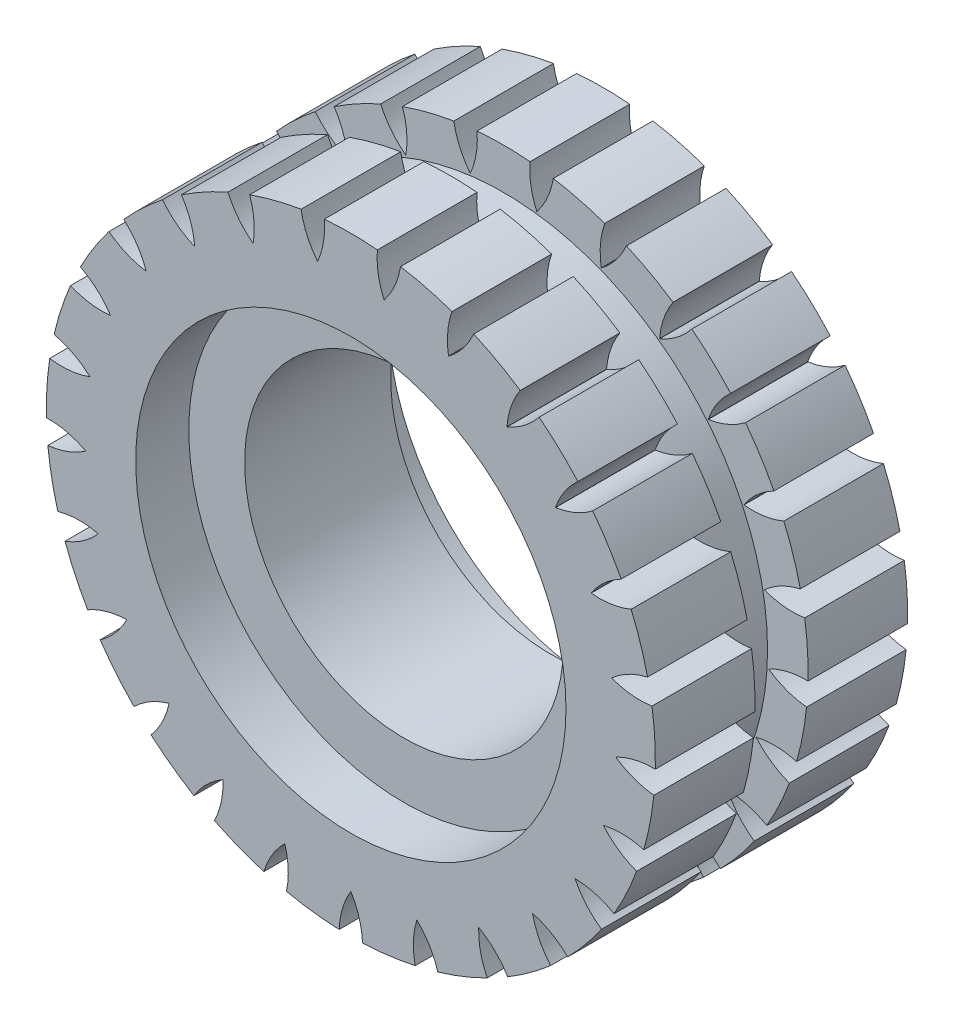
from build123d import *

# Parameters (mm, degrees)
AUFSATZ_LINEAR_AUSTRAGEN1_DEPTH = 19
SKIZZE3_W                       = 4
SKIZZE3_H                       = 3.501683852


with BuildPart() as part:
    # Skizze1 → Rotation1 (revolve)
    with BuildSketch(Plane(origin=(0, 0, 0), x_dir=(0, 0, -1), z_dir=(1, 0, 0))):
        Polygon((-5.5, 0), (5.5, 0), (5.5, 4.2), (9.5, 4.2), (9.5, 8), (-9.5, 8), (-9.5, 4.2), (-5.5, 4.2), align=None)
    revolve(axis=Axis((0, -12, 19.330416941), (0, 0, -1)))

    # Skizze2 → Aufsatz-Linear austragen1 (add, through all)
    with BuildSketch(Plane.XY.offset(9.5)):
        with BuildLine():
            ThreePointArc((-2.5, 7.843134833), (0, 8), (2.5, 7.843134833))
            ThreePointArc((2.5, 7.843134833), (2.059627906, 9.311406151), (2, 10.843134833))
            ThreePointArc((2, 10.843134833), (0, 10.930521342), (-2, 10.843134833))
            ThreePointArc((-2, 10.843134833), (-2.059627906, 9.311406151), (-2.5, 7.843134833))
        make_face()
        with BuildLine():
            ThreePointArc((3.743690302, 10.622855521), (5.702588765, 10.210116847), (7.618022946, 9.628095972))
            ThreePointArc((7.618022946, 9.628095972), (7.294852099, 8.129660506), (7.356244865, 6.598001545))
            ThreePointArc((7.356244865, 6.598001545), (4.973797743, 7.371663223), (2.51332906, 7.841450981))
            ThreePointArc((2.51332906, 7.841450981), (3.305010283, 9.154077769), (3.743690302, 10.622855521))
        make_face()
        with BuildLine():
            ThreePointArc((9.252150774, 8.981098995), (11.046862905, 8.094169029), (12.757377494, 7.054084299))
            ThreePointArc((12.757377494, 7.054084299), (12.071713906, 5.68309426), (11.750269812, 4.184287422))
            ThreePointArc((11.750269812, 4.184287422), (9.635073482, 5.526133601), (7.368736411, 6.593055792))
            ThreePointArc((7.368736411, 6.593055792), (8.461982521, 7.667560882), (9.252150774, 8.981098995))
        make_face()
        with BuildLine():
            ThreePointArc((14.179264585, 6.021022857), (15.697022022, 4.715630668), (17.095139095, 3.282834433))
            ThreePointArc((17.095139095, 3.282834433), (16.090065532, 2.125434168), (15.405982091, 0.753654998))
            ThreePointArc((15.405982091, 0.753654998), (13.690942119, 2.579372548), (11.761138954, 4.176390528))
            ThreePointArc((11.761138954, 4.176390528), (13.087257276, 4.945258813), (14.179264585, 6.021022857))
        make_face()
        with BuildLine():
            ThreePointArc((18.215443056, 1.928619576), (19.360879515, 0.286787758), (20.358750235, -1.448692126))
            ThreePointArc((20.358750235, -1.448692126), (19.097419165, -2.319778903), (18.093679856, -3.478336474))
            ThreePointArc((18.093679856, -3.478336474), (16.88655851, -1.2834641), (15.414545882, 0.743303154))
            ThreePointArc((15.414545882, 0.743303154), (16.890211525, 1.158223812), (18.215443056, 1.928619576))
        make_face()
        with BuildLine():
            ThreePointArc((21.107078247, -3.038970099), (21.808221744, -4.914079216), (22.343146224, -6.843196164))
            ThreePointArc((22.343146224, -6.843196164), (20.904811716, -7.373235867), (19.644485173, -8.245775406))
            ThreePointArc((19.644485173, -8.245775406), (19.021130326, -5.819660113), (18.099400201, -3.490492824))
            ThreePointArc((18.099400201, -3.490492824), (19.631891666, -3.455590784), (21.107078247, -3.038970099))
        make_face()
        with BuildLine():
            ThreePointArc((22.672478085, -8.569614239), (22.885273196, -10.560180652), (22.923640163, -12.561721153))
            ThreePointArc((22.923640163, -12.561721153), (21.398678065, -12.717409437), (19.960955238, -13.249106076))
            ThreePointArc((19.960955238, -13.249106076), (19.960534569, -10.744189609), (19.64700264, -8.258972434))
            ThreePointArc((19.64700264, -8.258972434), (21.140027853, -8.606282035), (22.672478085, -8.569614239))
        make_face()
        with BuildLine():
            ThreePointArc((22.813282742, -14.315802133), (22.524358766, -16.296751233), (22.063757484, -18.244951136))
            ThreePointArc((22.063757484, -18.244951136), (20.547986772, -18.016505534), (19.023205074, -18.173950817))
            ThreePointArc((19.023205074, -18.173950817), (19.645745015, -15.747626292), (19.960111647, -13.262514564))
            ThreePointArc((19.960111647, -13.262514564), (21.319858342, -13.970213067), (22.813282742, -14.315802133))
        make_face()
        with BuildLine():
            ThreePointArc((21.520644943, -19.916479661), (20.748156037, -21.763341132), (19.817527777, -23.535787871))
            ThreePointArc((19.817527777, -23.535787871), (18.4061899, -22.937562461), (16.890156974, -22.710863523))
            ThreePointArc((16.890156974, -22.710863523), (18.096541049, -20.515585831), (19.019053432, -18.18672826))
            ThreePointArc((19.019053432, -18.18672826), (20.160083722, -19.210348365), (21.520644943, -19.916479661))
        make_face()
        with BuildLine():
            ThreePointArc((18.875785875, -25.019735658), (17.668270357, -26.616464401), (16.326089916, -28.101788629))
            ThreePointArc((16.326089916, -28.101788629), (15.107864424, -27.171372113), (13.695838193, -26.574773281))
            ThreePointArc((13.695838193, -26.574773281), (15.410264856, -24.748479795), (16.882958141, -22.722207067))
            ThreePointArc((16.882958141, -22.722207067), (17.733576899, -23.997430959), (18.875785875, -25.019735658))
        make_face()
        with BuildLine():
            ThreePointArc((15.04489176, -29.30491378), (13.478222272, -30.551181455), (11.808823782, -31.656054789))
            ThreePointArc((11.808823782, -31.656054789), (10.860256263, -30.451908658), (9.640959528, -29.522896432))
            ThreePointArc((9.640959528, -29.522896432), (11.755705046, -28.180339887), (13.6860445, -26.583970171))
            ThreePointArc((13.6860445, -26.583970171), (14.192804219, -28.030670841), (15.04489176, -29.30491378))
        make_face()
        with BuildLine():
            ThreePointArc((10.268671764, -32.502760526), (8.441287912, -33.320259553), (6.549565821, -33.975258737))
            ThreePointArc((6.549565821, -33.975258737), (5.930258259, -32.573043922), (4.98030392, -31.369991556))
            ThreePointArc((4.98030392, -31.369991556), (7.362491054, -30.595529718), (9.629186349, -29.529368792))
            ThreePointArc((9.629186349, -29.529368792), (9.760245453, -31.056644718), (10.268671764, -32.502760526))
        make_face()
        with BuildLine():
            ThreePointArc((4.847233356, -34.412343425), (2.873956387, -34.749707332), (0.878774551, -34.913676359))
            ThreePointArc((0.878774551, -34.913676359), (0.62764032, -33.401499173), (0.006717499, -31.999998872))
            ThreePointArc((0.006717499, -31.999998872), (2.506664671, -31.842294026), (4.967291006, -31.373332704))
            ThreePointArc((4.967291006, -31.373332704), (4.71441457, -32.885219522), (4.847233356, -34.412343425))
        make_face()
        with BuildLine():
            ThreePointArc((-0.878774551, -34.913676359), (-2.873956387, -34.749707332), (-4.847233356, -34.412343425))
            ThreePointArc((-4.847233356, -34.412343425), (-4.71441457, -32.885219522), (-4.967291006, -31.373332704))
            ThreePointArc((-4.967291006, -31.373332704), (-2.506664671, -31.842294026), (-0.006717499, -31.999998872))
            ThreePointArc((-0.006717499, -31.999998872), (-0.62764032, -33.401499173), (-0.878774551, -34.913676359))
        make_face()
        with BuildLine():
            ThreePointArc((-6.549565821, -33.975258737), (-8.441287912, -33.320259553), (-10.268671764, -32.502760526))
            ThreePointArc((-10.268671764, -32.502760526), (-9.760245453, -31.056644718), (-9.629186349, -29.529368792))
            ThreePointArc((-9.629186349, -29.529368792), (-7.362491054, -30.595529718), (-4.98030392, -31.369991556))
            ThreePointArc((-4.98030392, -31.369991556), (-5.930258259, -32.573043922), (-6.549565821, -33.975258737))
        make_face()
        with BuildLine():
            ThreePointArc((-11.808823782, -31.656054789), (-13.478222272, -30.551181455), (-15.04489176, -29.30491378))
            ThreePointArc((-15.04489176, -29.30491378), (-14.192804219, -28.030670841), (-13.6860445, -26.583970171))
            ThreePointArc((-13.6860445, -26.583970171), (-11.755705046, -28.180339887), (-9.640959528, -29.522896432))
            ThreePointArc((-9.640959528, -29.522896432), (-10.860256263, -30.451908658), (-11.808823782, -31.656054789))
        make_face()
        with BuildLine():
            ThreePointArc((-16.326089916, -28.101788629), (-17.668270357, -26.616464401), (-18.875785875, -25.019735658))
            ThreePointArc((-18.875785875, -25.019735658), (-17.733576899, -23.997430959), (-16.882958141, -22.722207067))
            ThreePointArc((-16.882958141, -22.722207067), (-15.410264856, -24.748479795), (-13.695838193, -26.574773281))
            ThreePointArc((-13.695838193, -26.574773281), (-15.107864424, -27.171372113), (-16.326089916, -28.101788629))
        make_face()
        with BuildLine():
            ThreePointArc((-19.817527777, -23.535787871), (-20.748156037, -21.763341132), (-21.520644943, -19.916479661))
            ThreePointArc((-21.520644943, -19.916479661), (-20.160083722, -19.210348365), (-19.019053432, -18.18672826))
            ThreePointArc((-19.019053432, -18.18672826), (-18.096541049, -20.515585831), (-16.890156974, -22.710863523))
            ThreePointArc((-16.890156974, -22.710863523), (-18.4061899, -22.937562461), (-19.817527777, -23.535787871))
        make_face()
        with BuildLine():
            ThreePointArc((-22.063757484, -18.244951136), (-22.524358766, -16.296751233), (-22.813282742, -14.315802133))
            ThreePointArc((-22.813282742, -14.315802133), (-21.319858342, -13.970213067), (-19.960111647, -13.262514564))
            ThreePointArc((-19.960111647, -13.262514564), (-19.645745015, -15.747626292), (-19.023205074, -18.173950817))
            ThreePointArc((-19.023205074, -18.173950817), (-20.547986772, -18.016505534), (-22.063757484, -18.244951136))
        make_face()
        with BuildLine():
            ThreePointArc((-22.923640163, -12.561721153), (-22.885273196, -10.560180652), (-22.672478085, -8.569614239))
            ThreePointArc((-22.672478085, -8.569614239), (-21.140027853, -8.606282035), (-19.64700264, -8.258972434))
            ThreePointArc((-19.64700264, -8.258972434), (-19.960534569, -10.744189609), (-19.960955238, -13.249106076))
            ThreePointArc((-19.960955238, -13.249106076), (-21.398678065, -12.717409437), (-22.923640163, -12.561721153))
        make_face()
        with BuildLine():
            ThreePointArc((-22.343146224, -6.843196164), (-21.808221744, -4.914079216), (-21.107078247, -3.038970099))
            ThreePointArc((-21.107078247, -3.038970099), (-19.631891666, -3.455590784), (-18.099400201, -3.490492824))
            ThreePointArc((-18.099400201, -3.490492824), (-19.021130326, -5.819660113), (-19.644485173, -8.245775406))
            ThreePointArc((-19.644485173, -8.245775406), (-20.904811716, -7.373235867), (-22.343146224, -6.843196164))
        make_face()
        with BuildLine():
            ThreePointArc((-20.358750235, -1.448692126), (-19.360879515, 0.286787758), (-18.215443056, 1.928619576))
            ThreePointArc((-18.215443056, 1.928619576), (-16.890211525, 1.158223812), (-15.414545882, 0.743303154))
            ThreePointArc((-15.414545882, 0.743303154), (-16.88655851, -1.2834641), (-18.093679856, -3.478336474))
            ThreePointArc((-18.093679856, -3.478336474), (-19.097419165, -2.319778903), (-20.358750235, -1.448692126))
        make_face()
        with BuildLine():
            ThreePointArc((-17.095139095, 3.282834433), (-15.697022022, 4.715630668), (-14.179264585, 6.021022857))
            ThreePointArc((-14.179264585, 6.021022857), (-13.087257276, 4.945258813), (-11.761138954, 4.176390528))
            ThreePointArc((-11.761138954, 4.176390528), (-13.690942119, 2.579372548), (-15.405982091, 0.753654998))
            ThreePointArc((-15.405982091, 0.753654998), (-16.090065532, 2.125434168), (-17.095139095, 3.282834433))
        make_face()
        with BuildLine():
            ThreePointArc((-12.757377494, 7.054084299), (-11.046862905, 8.094169029), (-9.252150774, 8.981098995))
            ThreePointArc((-9.252150774, 8.981098995), (-8.461982521, 7.667560882), (-7.368736411, 6.593055792))
            ThreePointArc((-7.368736411, 6.593055792), (-9.635073482, 5.526133601), (-11.750269812, 4.184287422))
            ThreePointArc((-11.750269812, 4.184287422), (-12.071713906, 5.68309426), (-12.757377494, 7.054084299))
        make_face()
        with BuildLine():
            ThreePointArc((-7.618022946, 9.628095972), (-5.702588765, 10.210116847), (-3.743690302, 10.622855521))
            ThreePointArc((-3.743690302, 10.622855521), (-3.305010283, 9.154077769), (-2.51332906, 7.841450981))
            ThreePointArc((-2.51332906, 7.841450981), (-4.973797743, 7.371663223), (-7.356244865, 6.598001545))
            ThreePointArc((-7.356244865, 6.598001545), (-7.294852099, 8.129660506), (-7.618022946, 9.628095972))
        make_face()
    extrude(amount=-AUFSATZ_LINEAR_AUSTRAGEN1_DEPTH)

    # Skizze3 → Schnitt-Rotation2 (revolve, cut)
    with BuildSketch(Plane(origin=(0, 0, 0), x_dir=(0, 0, -1), z_dir=(1, 0, 0))):
        with Locations((0, 9.592292907)):
            Rectangle(SKIZZE3_W, SKIZZE3_H)
    revolve(axis=Axis((0, -12.035270763, 15.256951875), (0, 0, -1)), mode=Mode.SUBTRACT)


solid = part.part
